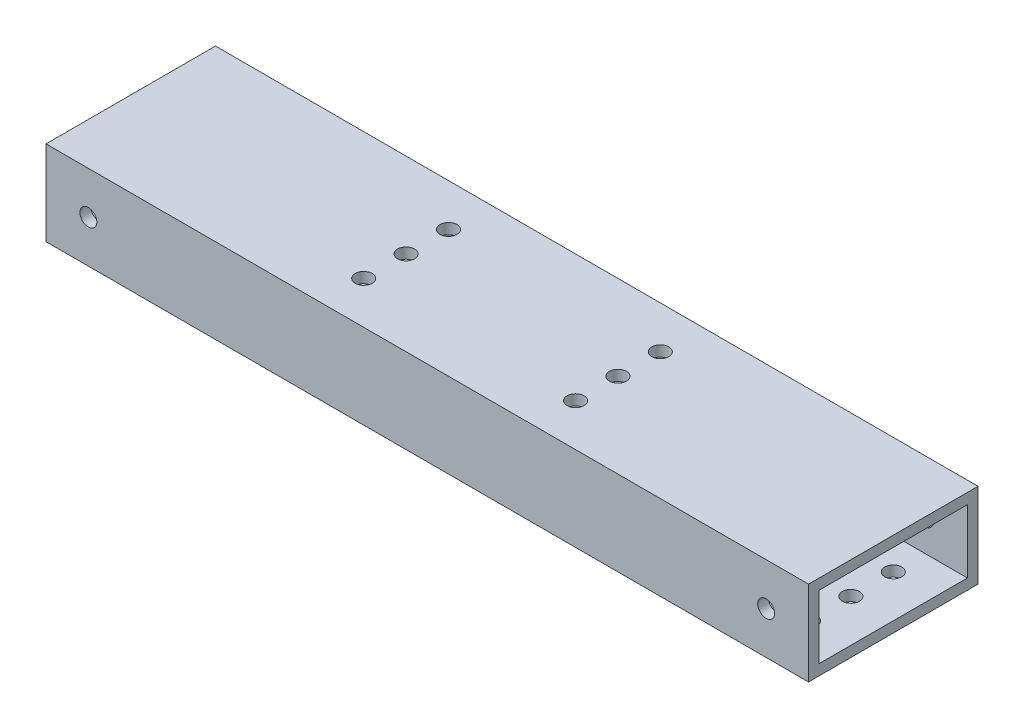
from build123d import *

# Parameters (mm, degrees)
SKETCH1_W                       = 50.8
SKETCH1_H                       = 25.4
SKETCH1_W_2                     = 44.45
SKETCH1_H_2                     = 19.05
EXTRUDE_THIN1_DEPTH             = 228.6
F_1_8_0_13_DIAMETER_HOLE1_D     = 3.302
F_1_8_0_13_DIAMETER_HOLE1_DEPTH = 3.175
F_10_CLEARANCE_HOLE1_D          = 5.1054
F_10_0_2_DIAMETER_HOLE1_D       = 5.08
F_10_CLEARANCE_HOLE2_D          = 5.1054
F_10_CLEARANCE_HOLE2_DEPTH      = 3.175


with BuildPart() as part:
    # Sketch1 → Extrude-Thin1 (new body)
    with BuildSketch(Plane(origin=(0, 0, 0), x_dir=(0, 0, -1), z_dir=(1, 0, 0))):
        Rectangle(SKETCH1_W, SKETCH1_H)
        Rectangle(SKETCH1_W_2, SKETCH1_H_2, mode=Mode.SUBTRACT)
    extrude(amount=EXTRUDE_THIN1_DEPTH)

    # 1/8 (0.13) Diameter Hole1
    with Locations(Plane(origin=(0, -12.7, 0), x_dir=(-1, 0, 0), z_dir=(0, -1, 0))):
        with Locations((-190.5, -15.875), (-38.1, -15.875), (-63.5, 15.875), (-88.9, -15.875), (-114.3, 15.875), (-139.7, -15.875), (-165.1, 15.875)):
            Hole(F_1_8_0_13_DIAMETER_HOLE1_D / 2, depth=F_1_8_0_13_DIAMETER_HOLE1_DEPTH)

    # #10 Clearance Hole1 (through all)
    with Locations(Plane(origin=(0, 12.7, 0), x_dir=(1, 0, 0), z_dir=(0, 1, 0))):
        with Locations((82.55, 12.7), (82.55, 0), (82.55, -12.7), (146.05, -12.7), (146.05, 0), (146.05, 12.7)):
            Hole(F_10_CLEARANCE_HOLE1_D / 2)

    # #10 (0.2) Diameter Hole1 (through all)
    with Locations(Plane.XY.offset(25.4)):
        with Locations((12.7, 0), (215.9, 0)):
            Hole(F_10_0_2_DIAMETER_HOLE1_D / 2)

    # #10 Clearance Hole2
    with Locations(Plane(origin=(0, -12.7, 0), x_dir=(-1, 0, 0), z_dir=(0, -1, 0))):
        with Locations((-215.9, 12.7), (-215.9, 0), (-215.9, -12.7), (-12.7, -12.7), (-12.7, 0), (-12.7, 12.7)):
            Hole(F_10_CLEARANCE_HOLE2_D / 2, depth=F_10_CLEARANCE_HOLE2_DEPTH)


solid = part.part
